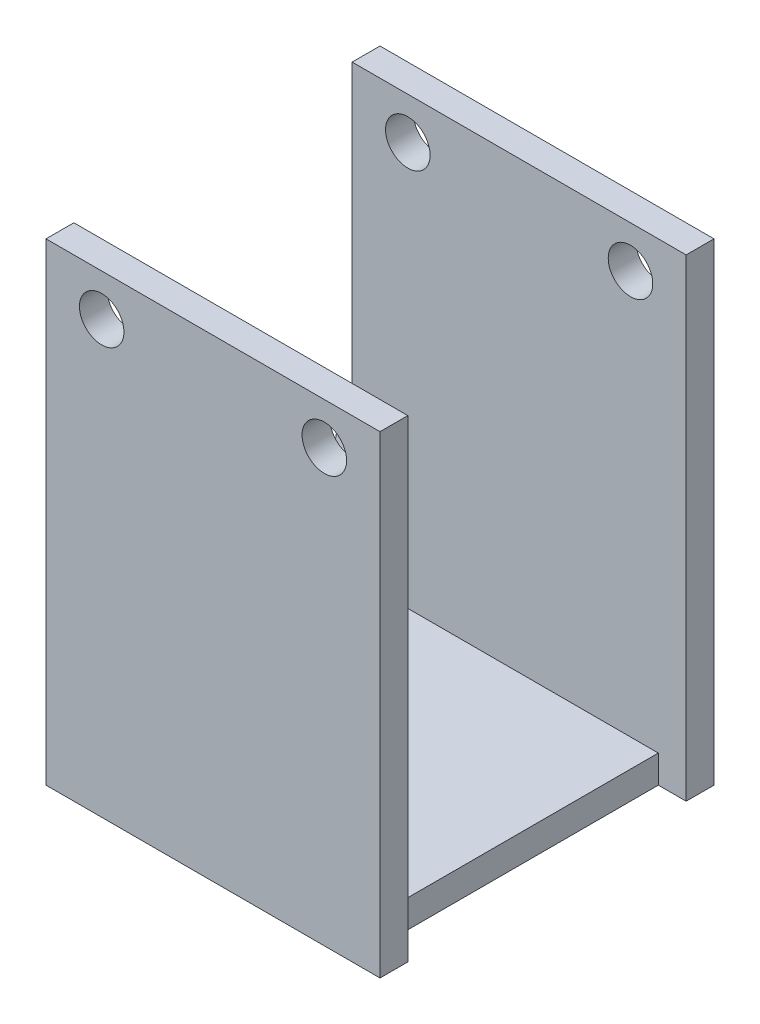
from build123d import *

# Parameters (mm, degrees)
SKETCH_1_W         = 10
SKETCH_1_H         = 10
EXTRUDE_1_DEPTH    = 1
EXTRUDE_2_DEPTH    = 1
SKETCH_4_W         = 12
SKETCH_4_H         = 17
EXTRUDE_4_DEPTH    = 1
SKETCH_5_W         = 12
SKETCH_5_H         = 17
EXTRUDE_5_DEPTH    = 1
HOLE_WIZARD_M2_1_D = 1.6


with BuildPart() as part:
    # 草图1 → 凸台-拉伸1 (new body)
    with BuildSketch(Plane(origin=(0, 0, 0), x_dir=(1, 0, 0), z_dir=(0, 1, 0))):
        with Locations((5, 5)):
            Rectangle(SKETCH_1_W, SKETCH_1_H)
    extrude(amount=EXTRUDE_1_DEPTH)

    # 草图2 → 凸台-拉伸2 (add)
    with BuildSketch(Plane.ZY):
        with BuildLine():
            Line((-9.5, 6.5), (-10, 6.5))
            Line((-10, 6.5), (-10, 0))
            Line((-10, 0), (0, 0))
            Line((0, 0), (0, 6.5))
            Line((0, 6.5), (-0.5, 6.5))
            ThreePointArc((-0.5, 6.5), (-5, 2), (-9.5, 6.5))
        make_face()
    extrude(amount=EXTRUDE_2_DEPTH)

    # 草图4 → 凸台-拉伸4 (add)
    with BuildSketch(Plane.XY):
        with Locations((5, 8.5)):
            Rectangle(SKETCH_4_W, SKETCH_4_H)
    extrude(amount=EXTRUDE_4_DEPTH)

    # 草图5 → 凸台-拉伸5 (add)
    with BuildSketch(Plane(origin=(0, 0, -10), x_dir=(-1, 0, 0), z_dir=(0, 0, -1))):
        with Locations((-5, 8.5)):
            Rectangle(SKETCH_5_W, SKETCH_5_H)
    extrude(amount=EXTRUDE_5_DEPTH)

    # M2 螺纹孔1 (through all)
    with Locations(Plane(origin=(0, 0, -11), x_dir=(-1, 0, 0), z_dir=(0, 0, -1))):
        with Locations((-9, 15.5), (-1, 15.5)):
            Hole(HOLE_WIZARD_M2_1_D / 2)


solid = part.part
